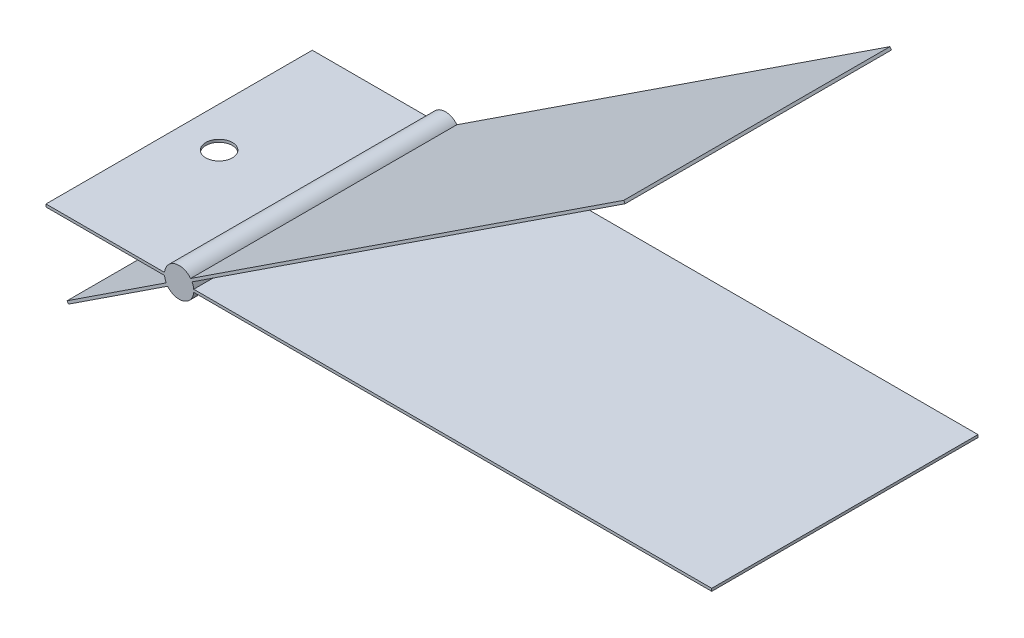
from build123d import *

# Parameters (mm, degrees)
EXTRUDE_1_DEPTH          = 20
CUT_EXTRUDE_1_DEPTH      = 20
CUT_EXTRUDE_1_DEPTH_BACK = 1
CUT_EXTRUDE_2_DEPTH      = 1


with BuildPart() as part:
    # 草图1 → 凸台-拉伸1 (new body)
    with BuildSketch(Plane.XY):
        with BuildLine():
            Line((1.095445115, 0.1), (40, 0.1))
            Line((40, 0.1), (40, -0.1))
            Line((40, -0.1), (1.095445115, -0.1))
            ThreePointArc((1.095445115, -0.1), (0.314917655, -1.053957718), (-0.861015843, -0.684581418))
            Line((-0.861015843, -0.684581418), (-8.30591358, -5.569721681))
            Line((-8.30591358, -5.569721681), (-8.415635859, -5.402506186))
            Line((-8.415635859, -5.402506186), (-0.970738122, -0.517365924))
            ThreePointArc((-0.970738122, -0.517365924), (-1.053957718, -0.314917655), (-1.095445115, -0.1))
            Line((-1.095445115, -0.1), (-10, -0.1))
            Line((-10, -0.1), (-10, 0.1))
            Line((-10, 0.1), (-1.095445115, 0.1))
            ThreePointArc((-1.095445115, 0.1), (-0.314917655, 1.053957718), (0.861015843, 0.684581418))
            Line((0.861015843, 0.684581418), (33.388237738, 22.028063482))
            Line((33.388237738, 22.028063482), (33.497960016, 21.860847988))
            Line((33.497960016, 21.860847988), (0.970738122, 0.517365924))
            ThreePointArc((0.970738122, 0.517365924), (1.053957718, 0.314917655), (1.095445115, 0.1))
        make_face()
    extrude(amount=EXTRUDE_1_DEPTH)

    # 草图2 → 切除-拉伸1 (cut, two sides)
    with BuildSketch(Plane(origin=(0, 0.1, 0), x_dir=(1, 0, 0), z_dir=(0, 1, 0))) as cut_extrude_1_sk:
        with BuildLine():
            ThreePointArc((-6, -10), (-7, -9), (-8, -10))
            Line((-8, -10), (-6, -10))
        make_face()
        with BuildLine():
            Line((-6, -10), (-8, -10))
            ThreePointArc((-8, -10), (-7, -11), (-6, -10))
        make_face()
    extrude(amount=CUT_EXTRUDE_1_DEPTH, mode=Mode.SUBTRACT)
    extrude(cut_extrude_1_sk.sketch, amount=-CUT_EXTRUDE_1_DEPTH_BACK, mode=Mode.SUBTRACT)

    # 草图3 → 切除-拉伸2 (cut)
    with BuildSketch(Plane(origin=(0.054861139, -0.083607747, 0), x_dir=(0.836077472, 0.548611393, 0), z_dir=(0.548611393, -0.836077472, 0))):
        with BuildLine():
            ThreePointArc((-6, 10), (-7, 11), (-8, 10))
            Line((-8, 10), (-6, 10))
        make_face()
        with BuildLine():
            Line((-6, 10), (-8, 10))
            ThreePointArc((-8, 10), (-7, 9), (-6, 10))
        make_face()
    extrude(amount=-CUT_EXTRUDE_2_DEPTH, mode=Mode.SUBTRACT)


solid = part.part
